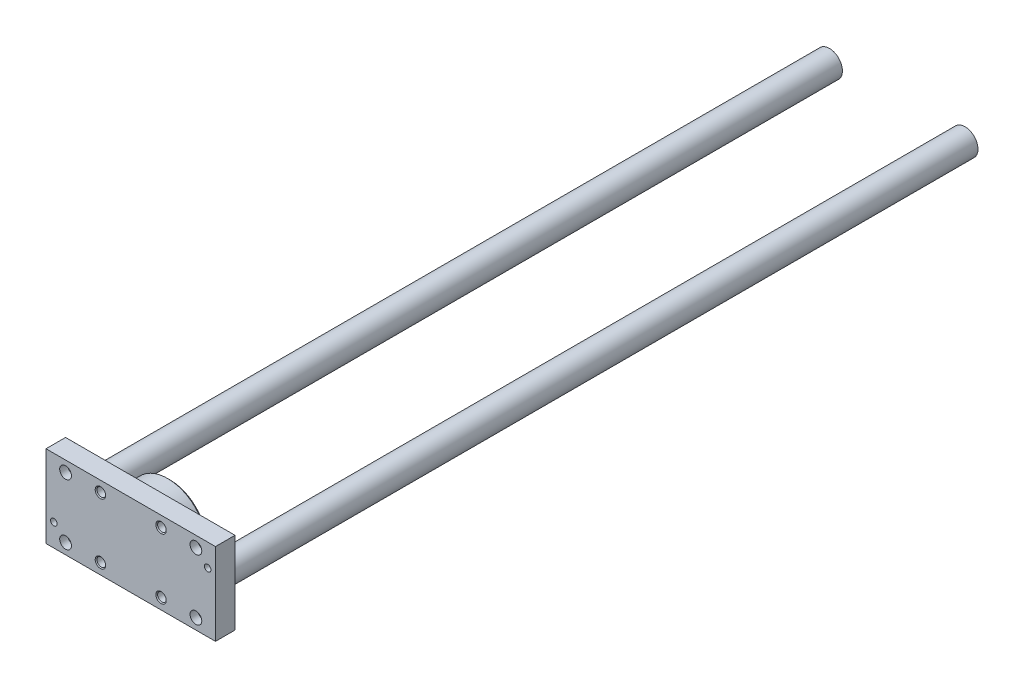
from build123d import *

# Parameters (mm, degrees)
SKETCH1_W            = 130
SKETCH1_H            = 63
BOSS_EXTRUDE1_DEPTH  = 15
LPATTERN1_COUNT      = 2
LPATTERN1_PITCH      = 46.5
LPATTERN1_COUNT_DIR2 = 2
LPATTERN1_PITCH_DIR2 = 46.5
LPATTERN2_COUNT      = 2
LPATTERN2_PITCH      = 100
LPATTERN2_COUNT_DIR2 = 2
LPATTERN2_PITCH_DIR2 = 46.5
SKETCH6_R            = 10
BOSS_EXTRUDE2_DEPTH  = 588
SKETCH7_R            = 10
BOSS_EXTRUDE3_DEPTH  = 588
SKETCH10_W           = 40
SKETCH10_H           = 40
SKETCH10_W_2         = 18
SKETCH10_H_2         = 30
CUT_EXTRUDE1_DEPTH   = 10
SKETCH11_R           = 2.5
CUT_EXTRUDE2_DEPTH   = 578.534630996


with BuildPart() as part:
    # Sketch1 → Boss-Extrude1 (new body)
    with BuildSketch(Plane.XY.offset(89)):
        Rectangle(SKETCH1_W, SKETCH1_H)
    extrude(amount=-BOSS_EXTRUDE1_DEPTH)

    # Sketch2 → Cut-Revolve1 (revolve, cut)
    with BuildSketch(Plane(origin=(23.25, 0, 0), x_dir=(0, 0, -1), z_dir=(1, 0, 0))):
        Polygon((-89, 23.25), (-89, 27.25), (-88.3235, 26.5735), (-74.6765, 26.5735), (-74, 27.25), (-74, 23.25), align=None)
    cut_revolve1 = revolve(axis=Axis((23.25, 23.25, 74), (0, 0, 1)), mode=Mode.SUBTRACT)

    # LPattern1: Cut-Revolve1 2 × 2
    with Locations(*[(-i * LPATTERN1_PITCH, -j * LPATTERN1_PITCH_DIR2, 0) for i in range(LPATTERN1_COUNT) for j in range(LPATTERN1_COUNT_DIR2) if (i, j) != (0, 0)]):
        add(cut_revolve1, mode=Mode.SUBTRACT)

    # Sketch4 → Cut-Revolve2 (revolve, cut)
    with BuildSketch(Plane(origin=(50, 0, 0), x_dir=(0, 0, -1), z_dir=(1, 0, 0))):
        Polygon((-89, 23.25), (-89, 27.75), (-83, 27.75), (-83, 30.75), (-74, 30.75), (-74, 23.25), align=None)
    cut_revolve2 = revolve(axis=Axis((50, 23.25, 74), (0, 0, 1)), mode=Mode.SUBTRACT)

    # LPattern2: Cut-Revolve2 2 × 2
    with Locations(*[(-i * LPATTERN2_PITCH, -j * LPATTERN2_PITCH_DIR2, 0) for i in range(LPATTERN2_COUNT) for j in range(LPATTERN2_COUNT_DIR2) if (i, j) != (0, 0)]):
        add(cut_revolve2, mode=Mode.SUBTRACT)

    # Sketch6 → Boss-Extrude2 (add)
    with BuildSketch(Plane.XY.offset(89)):
        with Locations((-52, 0)):
            Circle(SKETCH6_R)
    extrude(amount=-BOSS_EXTRUDE2_DEPTH)

    # Sketch7 → Boss-Extrude3 (add)
    with BuildSketch(Plane.XY.offset(89)):
        with Locations((52, 0)):
            Circle(SKETCH7_R)
    extrude(amount=-BOSS_EXTRUDE3_DEPTH)

    # Sketch8 → Revolve1 (revolve)
    with BuildSketch(Plane(origin=(0, 0, 0), x_dir=(0, 0, -1), z_dir=(1, 0, 0))):
        Polygon((-74, 0), (-74, 30), (-60.6, 30), (-59, 28.4), (-59, 11), (-50, 11), (-49, 10), (-49, 0), align=None)
    revolve(axis=Axis((0, 0, 49), (0, 0, 1)))

    # Sketch9 → Cut-Revolve3 (revolve, cut)
    with BuildSketch(Plane(origin=(0, 0, 0), x_dir=(0, 0, -1), z_dir=(1, 0, 0))):
        Polygon((-74, 0), (-74, 7.188), (-49.812, 7.188), (-49, 8), (-49, 0), align=None)
    revolve(axis=Axis((0, 0, 49), (0, 0, 1)), mode=Mode.SUBTRACT)

    # Sketch10 → Cut-Extrude1 (cut)
    with BuildSketch(Plane.XY.offset(49)):
        Rectangle(SKETCH10_W, SKETCH10_H)
        Rectangle(SKETCH10_W_2, SKETCH10_H_2, mode=Mode.SUBTRACT)
    extrude(amount=CUT_EXTRUDE1_DEPTH, mode=Mode.SUBTRACT)

    # Sketch11 → Cut-Extrude2 (cut, through all)
    with BuildSketch(Plane(origin=(0, 0, 74), x_dir=(-1, 0, 0), z_dir=(0, 0, -1))):
        with Locations((-59, 14.25)):
            Circle(SKETCH11_R)
        with Locations((59, -14.25)):
            Circle(SKETCH11_R)
    extrude(amount=-CUT_EXTRUDE2_DEPTH, mode=Mode.SUBTRACT)


solid = part.part
